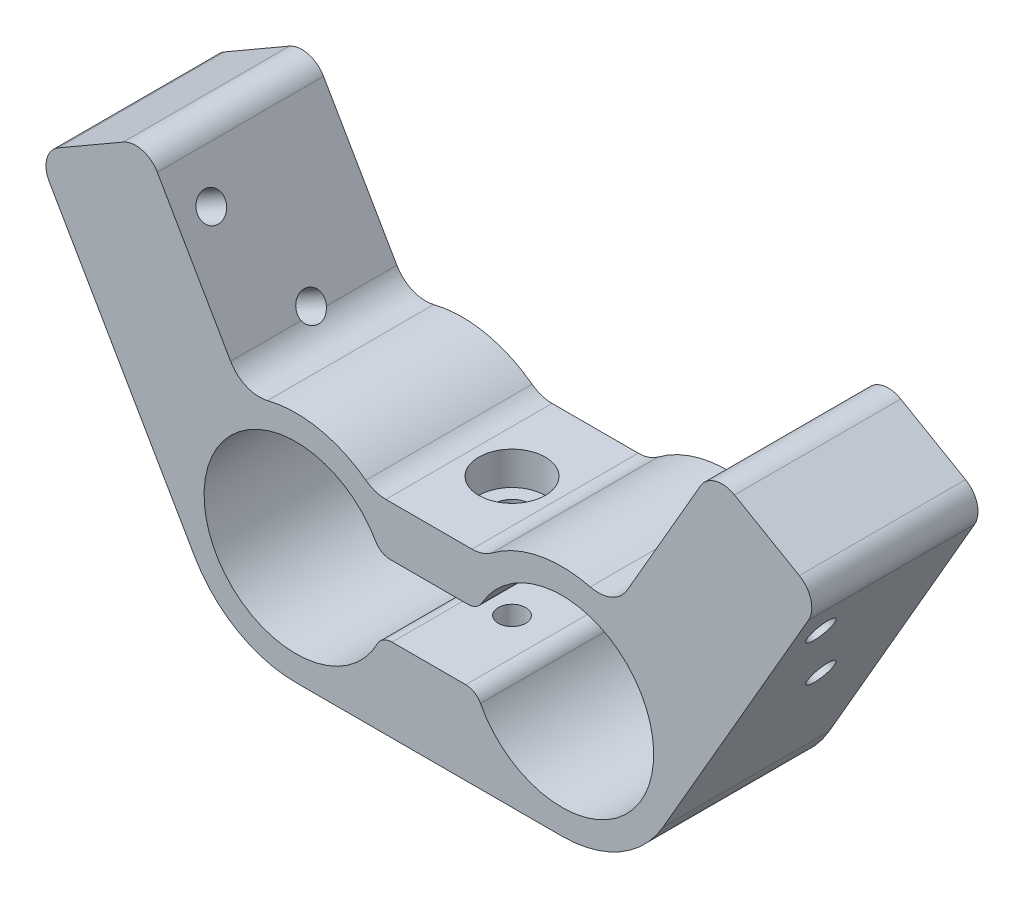
from build123d import *

# Parameters (mm, degrees)
EXTRUDE_2_DEPTH             = 20
HOLE_WIZARD_M41_D           = 4.5
HOLE_WIZARD_M41_DEPTH       = 6
HOLE_WIZARD_M41_CBORE_D     = 8
HOLE_WIZARD_M41_CBORE_DEPTH = 4
M4X0_71_D                   = 3.3
FILLET_1_R                  = 2
FILLET_2_R                  = 4
M4X0_72_D                   = 3.3
FILLET_3_R                  = 3


with BuildPart() as part:
    # Эскиз1 → Бобышка-Вытянуть2 (new body)
    with BuildSketch(Plane.XY):
        with BuildLine():
            Line((-6.608514495, 10.45), (6.608514495, 10.45))
            ThreePointArc((6.608514495, 10.45), (14.066074726, 13.916265053), (22.186198751, 12.614810542))
            Line((22.186198751, 12.614810542), (34.177275866, 33.383965344))
            Line((34.177275866, 33.383965344), (47.167656923, 25.883965344))
            Line((47.167656923, 25.883965344), (28.167656923, -7.025))
            ThreePointArc((28.167656923, -7.025), (23.025, -12.167656923), (16, -14.05))
            Line((16, -14.05), (-16, -14.05))
            ThreePointArc((-16, -14.05), (-23.025, -12.167656923), (-28.167656923, -7.025))
            Line((-28.167656923, -7.025), (-47.167656923, 25.883965344))
            Line((-47.167656923, 25.883965344), (-34.177275866, 33.383965344))
            Line((-34.177275866, 33.383965344), (-22.186198751, 12.614810542))
            ThreePointArc((-22.186198751, 12.614810542), (-14.066074726, 13.916265053), (-6.608514495, 10.45))
        make_face()
        with BuildLine():
            Line((-5.885653753, 4.45), (5.885653753, 4.45))
            ThreePointArc((5.885653753, 4.45), (27.047875471, -0.216673901), (5.71894947, -4.05))
            Line((5.71894947, -4.05), (-5.71894947, -4.05))
            ThreePointArc((-5.71894947, -4.05), (-27.047875471, -0.216673901), (-5.885653753, 4.45))
        make_face(mode=Mode.SUBTRACT)
    extrude(amount=EXTRUDE_2_DEPTH)

    # Цековка для винта с внутренним шестигранником M41
    with Locations(Plane(origin=(0, 10.45, 0), x_dir=(1, 0, 0), z_dir=(0, 1, 0))):
        with Locations((0, -10)):
            CounterBoreHole(HOLE_WIZARD_M41_D / 2, HOLE_WIZARD_M41_CBORE_D / 2, HOLE_WIZARD_M41_CBORE_DEPTH, depth=HOLE_WIZARD_M41_DEPTH)

    # Отверстие обработанное метчиком M4x0.71 (through all)
    with Locations(Plane(origin=(0, -4.05, 0), x_dir=(1, 0, 0), z_dir=(0, 1, 0))):
        with Locations((0, -10)):
            Hole(M4X0_71_D / 2)

    # Скругление1
    fillet_1_edges = [part.edges().sort_by_distance(p)[0] for p in [
        (-5.885653753, 4.45, 10),
        (-5.71894947, -4.05, 10),
        (5.71894947, -4.05, 10),
        (5.885653753, 4.45, 10),
    ]]
    fillet(fillet_1_edges, radius=FILLET_1_R)

    # Скругление2
    fillet_2_edges = [part.edges().sort_by_distance(p)[0] for p in [
        (-6.608514495, 10.45, 10),
        (6.608514495, 10.45, 10),
        (22.186198751, 12.614810542, 10),
        (-22.186198751, 12.614810542, 10),
    ]]
    fillet(fillet_2_edges, radius=FILLET_2_R)

    # Отверстие обработанное метчиком M4x0.72 (through all)
    with Locations(Plane(origin=(24.167656923, -13.95320323, 0), x_dir=(0, 0, -1), z_dir=(0.866025404, -0.5, 0))):
        with Locations((-10, 26), (-16, 38)):
            m4x0_72 = Hole(M4X0_72_D / 2)

    # Зеркальное отражение1: Отверстие обработанное метчиком M4x0.72 across plane
    add(m4x0_72.mirror(Plane(origin=(0, 0, 0), x_dir=(0, 0, 1), z_dir=(1, 0, 0))), mode=Mode.SUBTRACT)

    # Скругление3
    fillet_3_edges = [part.edges().sort_by_distance(p)[0] for p in [
        (34.177275866, 33.383965344, 10),
        (47.167656923, 25.883965344, 10),
        (-47.167656923, 25.883965344, 10),
        (-34.177275866, 33.383965344, 10),
    ]]
    fillet(fillet_3_edges, radius=FILLET_3_R)


solid = part.part
